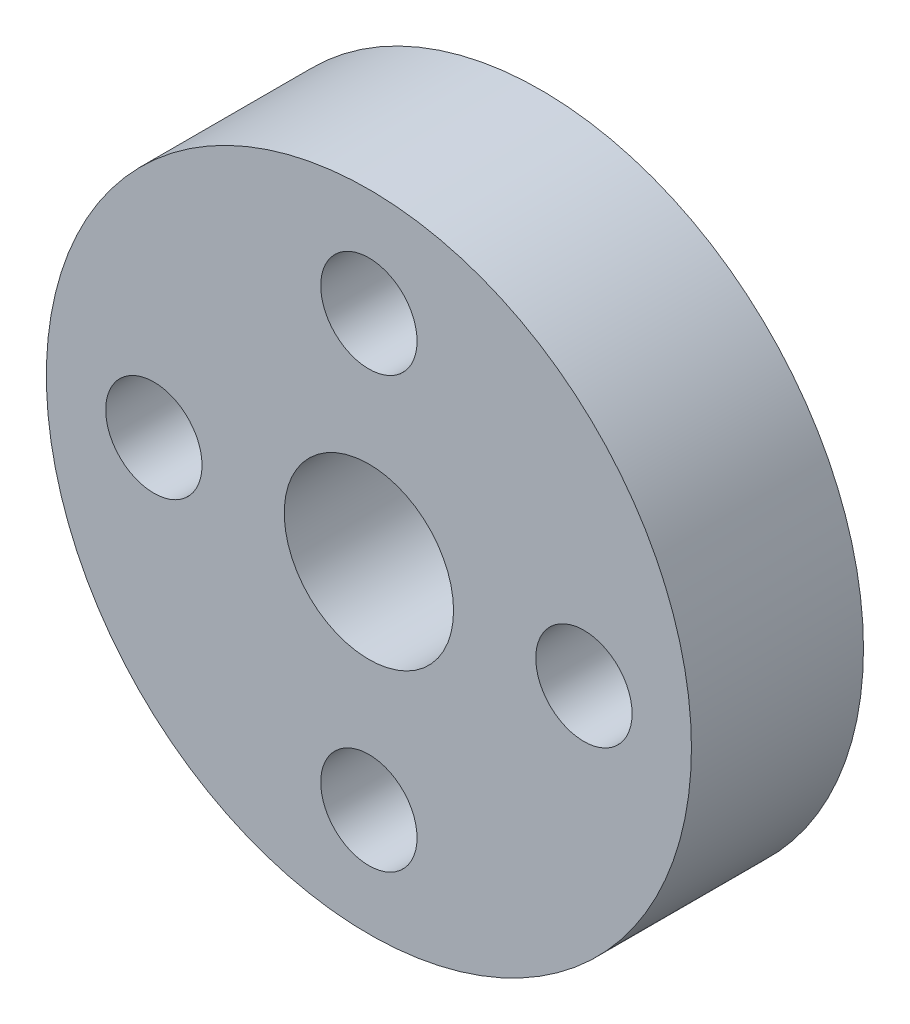
from build123d import *

# Parameters (mm, degrees)
SKETCH1_R           = 9.525
SKETCH1_R_2         = 2.5
SKETCH1_R_3         = 1.4225
BOSS_EXTRUDE1_DEPTH = 5.08


with BuildPart() as part:
    # Sketch1 → Boss-Extrude1 (new body)
    with BuildSketch(Plane.XY):
        with Locations((-49.26695237, 24.921587018)):
            Circle(SKETCH1_R)
        with Locations((-49.26695237, 24.921587018)):
            Circle(SKETCH1_R_2, mode=Mode.SUBTRACT)
        with Locations((-49.26695237, 31.271587018)):
            Circle(SKETCH1_R_3, mode=Mode.SUBTRACT)
        with Locations((-42.91695237, 24.921587018)):
            Circle(SKETCH1_R_3, mode=Mode.SUBTRACT)
        with Locations((-49.26695237, 18.571587018)):
            Circle(SKETCH1_R_3, mode=Mode.SUBTRACT)
        with Locations((-55.61695237, 24.921587018)):
            Circle(SKETCH1_R_3, mode=Mode.SUBTRACT)
    extrude(amount=BOSS_EXTRUDE1_DEPTH)


solid = part.part
